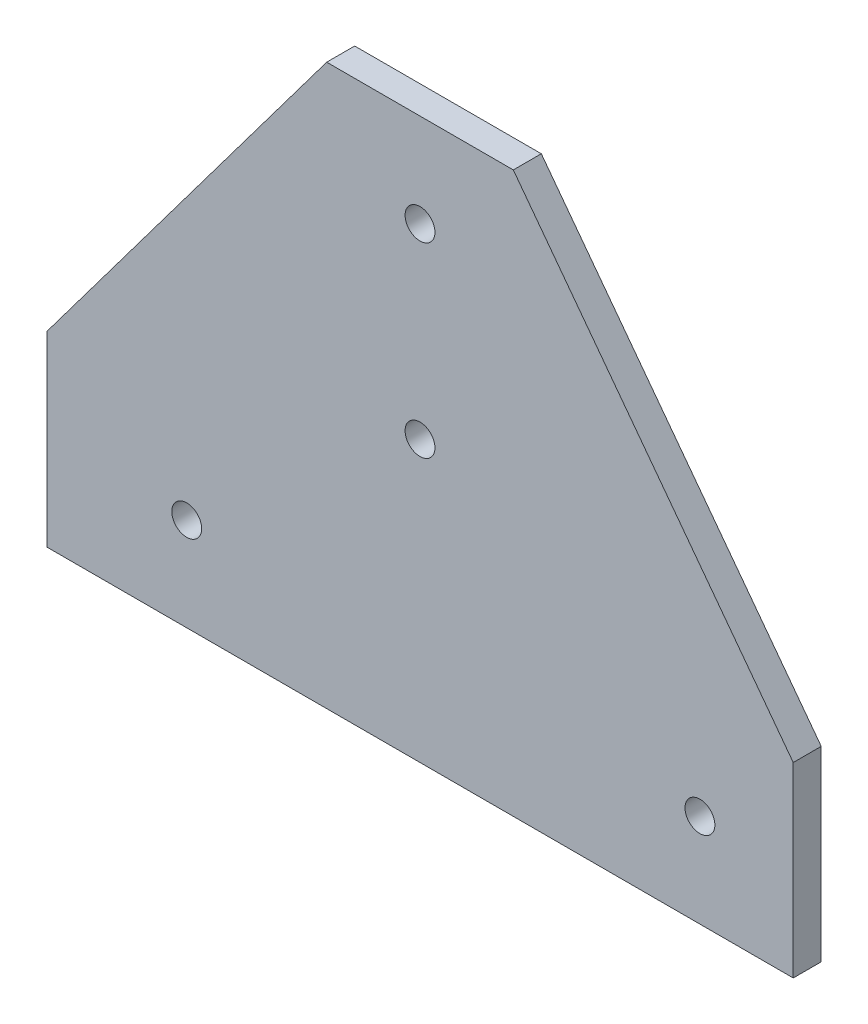
from build123d import *

# Parameters (mm, degrees)
SKETCH1_R      = 1.6
EXTRUDE1_DEPTH = 3


with BuildPart() as part:
    # Sketch1 → Extrude1 (new body)
    with BuildSketch(Plane.XY):
        Polygon((453.489921235, 0), (453.489921235, 20), (423.489921235, 60), (403.489921235, 60), (373.489921235, 20), (373.489921235, 0), align=None)
        with Locations((413.489921235, 50)):
            Circle(SKETCH1_R, mode=Mode.SUBTRACT)
        with Locations((413.489921235, 30)):
            Circle(SKETCH1_R, mode=Mode.SUBTRACT)
        with Locations((443.489921235, 10)):
            Circle(SKETCH1_R, mode=Mode.SUBTRACT)
        with Locations((388.489921235, 10)):
            Circle(SKETCH1_R, mode=Mode.SUBTRACT)
    extrude(amount=EXTRUDE1_DEPTH)


solid = part.part
